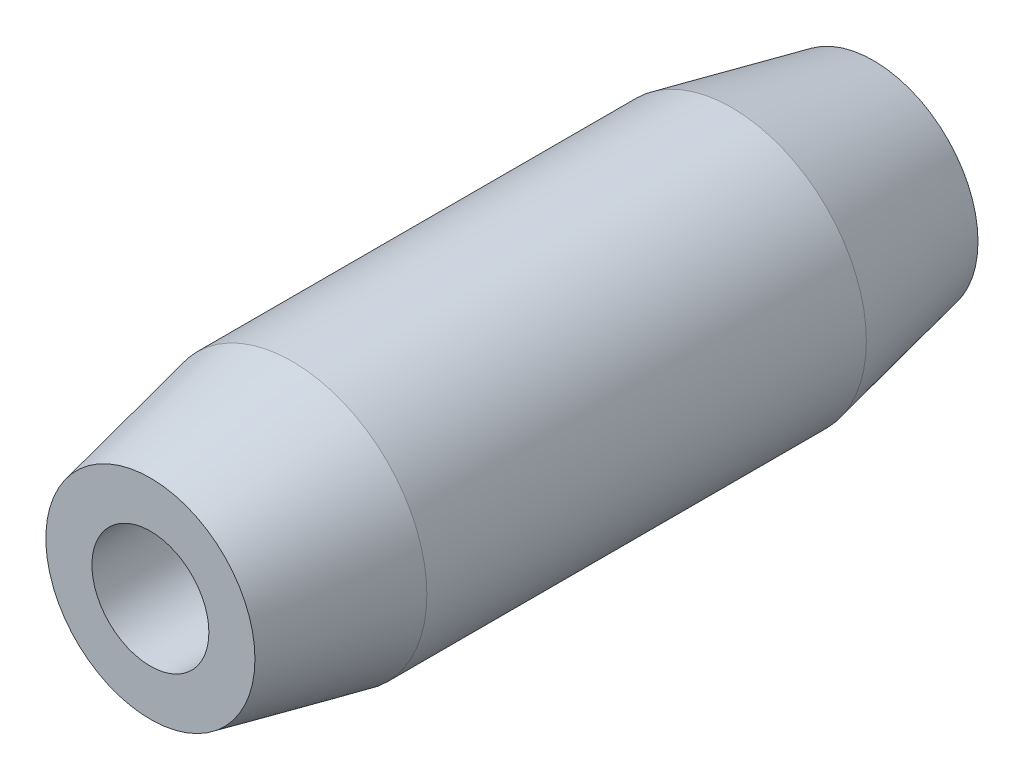
from build123d import *

# Parameters (mm, degrees)
SKETCH1_R           = 3.8
SKETCH1_R_2         = 1.65
BOSS_EXTRUDE1_DEPTH = 20.4
CHAMFER1_SIZE       = 4
CHAMFER1_SIZE2      = 0.850226247
CHAMFER2_SIZE       = 4
CHAMFER2_SIZE2      = 0.850226247


with BuildPart() as part:
    # Sketch1 → Boss-Extrude1 (new body)
    with BuildSketch(Plane.XY):
        Circle(SKETCH1_R)
        Circle(SKETCH1_R_2, mode=Mode.SUBTRACT)
    extrude(amount=BOSS_EXTRUDE1_DEPTH)

    # Chamfer1
    chamfer1_edges = [part.edges().sort_by_distance(p)[0] for p in [
        (-3.8, 0, 20.4),
    ]]
    chamfer1_side = [part.faces().sort_by_distance(p)[0] for p in [
        (-3.8, 0, 10.2),
    ]]
    chamfer(chamfer1_edges, length=CHAMFER1_SIZE, length2=CHAMFER1_SIZE2, reference=chamfer1_side[0])

    # Chamfer2
    chamfer2_edges = [part.edges().sort_by_distance(p)[0] for p in [
        (-3.8, 0, 0),
    ]]
    chamfer2_side = [part.faces().sort_by_distance(p)[0] for p in [
        (-3.8, 0, 8.2),
    ]]
    chamfer(chamfer2_edges, length=CHAMFER2_SIZE, length2=CHAMFER2_SIZE2, reference=chamfer2_side[0])


solid = part.part
